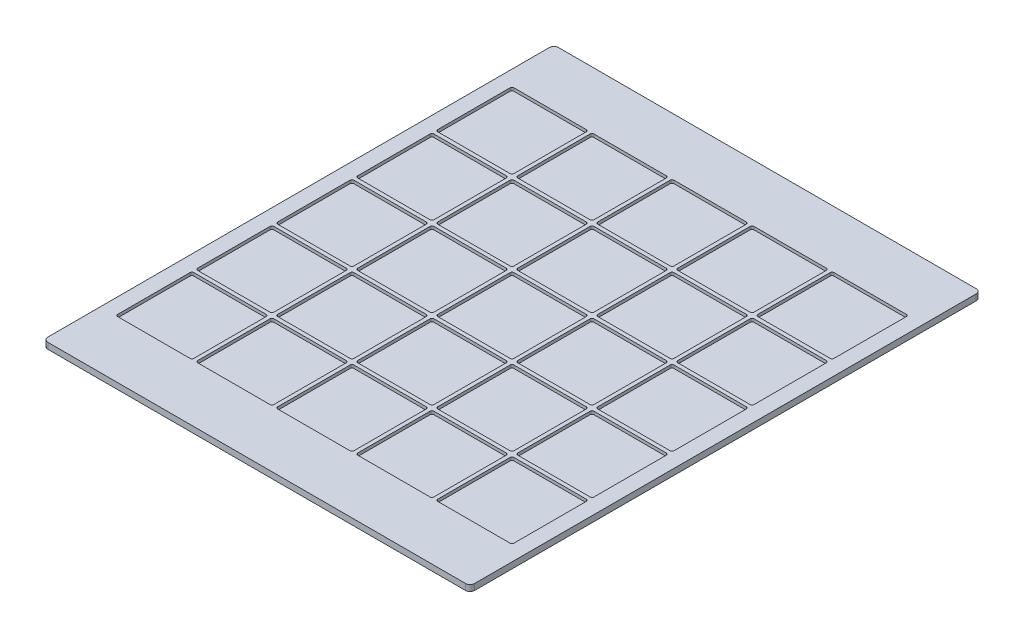
from build123d import *

# Parameters (mm, degrees)
SKETCH1_W           = 711.2
SKETCH1_H           = 850.9
BOSS_EXTRUDE1_DEPTH = 5.08
SKETCH2_W           = 711.2
SKETCH2_H           = 850.9
BOSS_EXTRUDE2_DEPTH = 5.08
FILLET1_R           = 7.62


with BuildPart() as part:
    # Sketch1 → Boss-Extrude1 (new body)
    with BuildSketch(Plane(origin=(0, 0, 0), x_dir=(1, 0, 0), z_dir=(0, 1, 0))):
        Rectangle(SKETCH1_W, SKETCH1_H)
        with BuildLine():
            Line((-193.675, 203.2), (-73.025, 203.2))
            ThreePointArc((-73.025, 203.2), (-70.77993597, 204.12993597), (-69.85, 206.375))
            Line((-69.85, 206.375), (-69.85, 327.025))
            ThreePointArc((-69.85, 327.025), (-70.77993597, 329.27006403), (-73.025, 330.2))
            Line((-73.025, 330.2), (-193.675, 330.2))
            ThreePointArc((-193.675, 330.2), (-195.92006403, 329.27006403), (-196.85, 327.025))
            Line((-196.85, 327.025), (-196.85, 206.375))
            ThreePointArc((-196.85, 206.375), (-195.92006403, 204.12993597), (-193.675, 203.2))
        make_face(mode=Mode.SUBTRACT)
        with BuildLine():
            Line((-327.025, 203.2), (-206.375, 203.2))
            ThreePointArc((-206.375, 203.2), (-204.12993597, 204.12993597), (-203.2, 206.375))
            Line((-203.2, 206.375), (-203.2, 327.025))
            ThreePointArc((-203.2, 327.025), (-204.12993597, 329.27006403), (-206.375, 330.2))
            Line((-206.375, 330.2), (-327.025, 330.2))
            ThreePointArc((-327.025, 330.2), (-329.27006403, 329.27006403), (-330.2, 327.025))
            Line((-330.2, 327.025), (-330.2, 206.375))
            ThreePointArc((-330.2, 206.375), (-329.27006403, 204.12993597), (-327.025, 203.2))
        make_face(mode=Mode.SUBTRACT)
        with BuildLine():
            Line((-60.325, 203.2), (60.325, 203.2))
            ThreePointArc((60.325, 203.2), (62.57006403, 204.12993597), (63.5, 206.375))
            Line((63.5, 206.375), (63.5, 327.025))
            ThreePointArc((63.5, 327.025), (62.57006403, 329.27006403), (60.325, 330.2))
            Line((60.325, 330.2), (-60.325, 330.2))
            ThreePointArc((-60.325, 330.2), (-62.57006403, 329.27006403), (-63.5, 327.025))
            Line((-63.5, 327.025), (-63.5, 206.375))
            ThreePointArc((-63.5, 206.375), (-62.57006403, 204.12993597), (-60.325, 203.2))
        make_face(mode=Mode.SUBTRACT)
        with BuildLine():
            Line((73.025, 203.2), (193.675, 203.2))
            ThreePointArc((193.675, 203.2), (195.92006403, 204.12993597), (196.85, 206.375))
            Line((196.85, 206.375), (196.85, 327.025))
            ThreePointArc((196.85, 327.025), (195.92006403, 329.27006403), (193.675, 330.2))
            Line((193.675, 330.2), (73.025, 330.2))
            ThreePointArc((73.025, 330.2), (70.77993597, 329.27006403), (69.85, 327.025))
            Line((69.85, 327.025), (69.85, 206.375))
            ThreePointArc((69.85, 206.375), (70.77993597, 204.12993597), (73.025, 203.2))
        make_face(mode=Mode.SUBTRACT)
        with BuildLine():
            Line((206.375, 203.2), (327.025, 203.2))
            ThreePointArc((327.025, 203.2), (329.27006403, 204.12993597), (330.2, 206.375))
            Line((330.2, 206.375), (330.2, 327.025))
            ThreePointArc((330.2, 327.025), (329.27006403, 329.27006403), (327.025, 330.2))
            Line((327.025, 330.2), (206.375, 330.2))
            ThreePointArc((206.375, 330.2), (204.12993597, 329.27006403), (203.2, 327.025))
            Line((203.2, 327.025), (203.2, 206.375))
            ThreePointArc((203.2, 206.375), (204.12993597, 204.12993597), (206.375, 203.2))
        make_face(mode=Mode.SUBTRACT)
        with BuildLine():
            Line((-193.675, 69.85), (-73.025, 69.85))
            ThreePointArc((-73.025, 69.85), (-70.77993597, 70.77993597), (-69.85, 73.025))
            Line((-69.85, 73.025), (-69.85, 193.675))
            ThreePointArc((-69.85, 193.675), (-70.77993597, 195.92006403), (-73.025, 196.85))
            Line((-73.025, 196.85), (-193.675, 196.85))
            ThreePointArc((-193.675, 196.85), (-195.92006403, 195.92006403), (-196.85, 193.675))
            Line((-196.85, 193.675), (-196.85, 73.025))
            ThreePointArc((-196.85, 73.025), (-195.92006403, 70.77993597), (-193.675, 69.85))
        make_face(mode=Mode.SUBTRACT)
        with BuildLine():
            Line((-60.325, 69.85), (60.325, 69.85))
            ThreePointArc((60.325, 69.85), (62.57006403, 70.77993597), (63.5, 73.025))
            Line((63.5, 73.025), (63.5, 193.675))
            ThreePointArc((63.5, 193.675), (62.57006403, 195.92006403), (60.325, 196.85))
            Line((60.325, 196.85), (-60.325, 196.85))
            ThreePointArc((-60.325, 196.85), (-62.57006403, 195.92006403), (-63.5, 193.675))
            Line((-63.5, 193.675), (-63.5, 73.025))
            ThreePointArc((-63.5, 73.025), (-62.57006403, 70.77993597), (-60.325, 69.85))
        make_face(mode=Mode.SUBTRACT)
        with BuildLine():
            Line((73.025, 69.85), (193.675, 69.85))
            ThreePointArc((193.675, 69.85), (195.92006403, 70.77993597), (196.85, 73.025))
            Line((196.85, 73.025), (196.85, 193.675))
            ThreePointArc((196.85, 193.675), (195.92006403, 195.92006403), (193.675, 196.85))
            Line((193.675, 196.85), (73.025, 196.85))
            ThreePointArc((73.025, 196.85), (70.77993597, 195.92006403), (69.85, 193.675))
            Line((69.85, 193.675), (69.85, 73.025))
            ThreePointArc((69.85, 73.025), (70.77993597, 70.77993597), (73.025, 69.85))
        make_face(mode=Mode.SUBTRACT)
        with BuildLine():
            Line((206.375, 69.85), (327.025, 69.85))
            ThreePointArc((327.025, 69.85), (329.27006403, 70.77993597), (330.2, 73.025))
            Line((330.2, 73.025), (330.2, 193.675))
            ThreePointArc((330.2, 193.675), (329.27006403, 195.92006403), (327.025, 196.85))
            Line((327.025, 196.85), (206.375, 196.85))
            ThreePointArc((206.375, 196.85), (204.12993597, 195.92006403), (203.2, 193.675))
            Line((203.2, 193.675), (203.2, 73.025))
            ThreePointArc((203.2, 73.025), (204.12993597, 70.77993597), (206.375, 69.85))
        make_face(mode=Mode.SUBTRACT)
        with BuildLine():
            Line((-193.675, -63.5), (-73.025, -63.5))
            ThreePointArc((-73.025, -63.5), (-70.77993597, -62.57006403), (-69.85, -60.325))
            Line((-69.85, -60.325), (-69.85, 60.325))
            ThreePointArc((-69.85, 60.325), (-70.77993597, 62.57006403), (-73.025, 63.5))
            Line((-73.025, 63.5), (-193.675, 63.5))
            ThreePointArc((-193.675, 63.5), (-195.92006403, 62.57006403), (-196.85, 60.325))
            Line((-196.85, 60.325), (-196.85, -60.325))
            ThreePointArc((-196.85, -60.325), (-195.92006403, -62.57006403), (-193.675, -63.5))
        make_face(mode=Mode.SUBTRACT)
        with BuildLine():
            Line((-60.325, -63.5), (60.325, -63.5))
            ThreePointArc((60.325, -63.5), (62.57006403, -62.57006403), (63.5, -60.325))
            Line((63.5, -60.325), (63.5, 60.325))
            ThreePointArc((63.5, 60.325), (62.57006403, 62.57006403), (60.325, 63.5))
            Line((60.325, 63.5), (-60.325, 63.5))
            ThreePointArc((-60.325, 63.5), (-62.57006403, 62.57006403), (-63.5, 60.325))
            Line((-63.5, 60.325), (-63.5, -60.325))
            ThreePointArc((-63.5, -60.325), (-62.57006403, -62.57006403), (-60.325, -63.5))
        make_face(mode=Mode.SUBTRACT)
        with BuildLine():
            Line((73.025, -63.5), (193.675, -63.5))
            ThreePointArc((193.675, -63.5), (195.92006403, -62.57006403), (196.85, -60.325))
            Line((196.85, -60.325), (196.85, 60.325))
            ThreePointArc((196.85, 60.325), (195.92006403, 62.57006403), (193.675, 63.5))
            Line((193.675, 63.5), (73.025, 63.5))
            ThreePointArc((73.025, 63.5), (70.77993597, 62.57006403), (69.85, 60.325))
            Line((69.85, 60.325), (69.85, -60.325))
            ThreePointArc((69.85, -60.325), (70.77993597, -62.57006403), (73.025, -63.5))
        make_face(mode=Mode.SUBTRACT)
        with BuildLine():
            Line((206.375, -63.5), (327.025, -63.5))
            ThreePointArc((327.025, -63.5), (329.27006403, -62.57006403), (330.2, -60.325))
            Line((330.2, -60.325), (330.2, 60.325))
            ThreePointArc((330.2, 60.325), (329.27006403, 62.57006403), (327.025, 63.5))
            Line((327.025, 63.5), (206.375, 63.5))
            ThreePointArc((206.375, 63.5), (204.12993597, 62.57006403), (203.2, 60.325))
            Line((203.2, 60.325), (203.2, -60.325))
            ThreePointArc((203.2, -60.325), (204.12993597, -62.57006403), (206.375, -63.5))
        make_face(mode=Mode.SUBTRACT)
        with BuildLine():
            Line((-193.675, -196.85), (-73.025, -196.85))
            ThreePointArc((-73.025, -196.85), (-70.77993597, -195.92006403), (-69.85, -193.675))
            Line((-69.85, -193.675), (-69.85, -73.025))
            ThreePointArc((-69.85, -73.025), (-70.77993597, -70.77993597), (-73.025, -69.85))
            Line((-73.025, -69.85), (-193.675, -69.85))
            ThreePointArc((-193.675, -69.85), (-195.92006403, -70.77993597), (-196.85, -73.025))
            Line((-196.85, -73.025), (-196.85, -193.675))
            ThreePointArc((-196.85, -193.675), (-195.92006403, -195.92006403), (-193.675, -196.85))
        make_face(mode=Mode.SUBTRACT)
        with BuildLine():
            Line((-60.325, -196.85), (60.325, -196.85))
            ThreePointArc((60.325, -196.85), (62.57006403, -195.92006403), (63.5, -193.675))
            Line((63.5, -193.675), (63.5, -73.025))
            ThreePointArc((63.5, -73.025), (62.57006403, -70.77993597), (60.325, -69.85))
            Line((60.325, -69.85), (-60.325, -69.85))
            ThreePointArc((-60.325, -69.85), (-62.57006403, -70.77993597), (-63.5, -73.025))
            Line((-63.5, -73.025), (-63.5, -193.675))
            ThreePointArc((-63.5, -193.675), (-62.57006403, -195.92006403), (-60.325, -196.85))
        make_face(mode=Mode.SUBTRACT)
        with BuildLine():
            Line((73.025, -196.85), (193.675, -196.85))
            ThreePointArc((193.675, -196.85), (195.92006403, -195.92006403), (196.85, -193.675))
            Line((196.85, -193.675), (196.85, -73.025))
            ThreePointArc((196.85, -73.025), (195.92006403, -70.77993597), (193.675, -69.85))
            Line((193.675, -69.85), (73.025, -69.85))
            ThreePointArc((73.025, -69.85), (70.77993597, -70.77993597), (69.85, -73.025))
            Line((69.85, -73.025), (69.85, -193.675))
            ThreePointArc((69.85, -193.675), (70.77993597, -195.92006403), (73.025, -196.85))
        make_face(mode=Mode.SUBTRACT)
        with BuildLine():
            Line((206.375, -196.85), (327.025, -196.85))
            ThreePointArc((327.025, -196.85), (329.27006403, -195.92006403), (330.2, -193.675))
            Line((330.2, -193.675), (330.2, -73.025))
            ThreePointArc((330.2, -73.025), (329.27006403, -70.77993597), (327.025, -69.85))
            Line((327.025, -69.85), (206.375, -69.85))
            ThreePointArc((206.375, -69.85), (204.12993597, -70.77993597), (203.2, -73.025))
            Line((203.2, -73.025), (203.2, -193.675))
            ThreePointArc((203.2, -193.675), (204.12993597, -195.92006403), (206.375, -196.85))
        make_face(mode=Mode.SUBTRACT)
        with BuildLine():
            Line((-193.675, -330.2), (-73.025, -330.2))
            ThreePointArc((-73.025, -330.2), (-70.77993597, -329.27006403), (-69.85, -327.025))
            Line((-69.85, -327.025), (-69.85, -206.375))
            ThreePointArc((-69.85, -206.375), (-70.77993597, -204.12993597), (-73.025, -203.2))
            Line((-73.025, -203.2), (-193.675, -203.2))
            ThreePointArc((-193.675, -203.2), (-195.92006403, -204.12993597), (-196.85, -206.375))
            Line((-196.85, -206.375), (-196.85, -327.025))
            ThreePointArc((-196.85, -327.025), (-195.92006403, -329.27006403), (-193.675, -330.2))
        make_face(mode=Mode.SUBTRACT)
        with BuildLine():
            Line((-60.325, -330.2), (60.325, -330.2))
            ThreePointArc((60.325, -330.2), (62.57006403, -329.27006403), (63.5, -327.025))
            Line((63.5, -327.025), (63.5, -206.375))
            ThreePointArc((63.5, -206.375), (62.57006403, -204.12993597), (60.325, -203.2))
            Line((60.325, -203.2), (-60.325, -203.2))
            ThreePointArc((-60.325, -203.2), (-62.57006403, -204.12993597), (-63.5, -206.375))
            Line((-63.5, -206.375), (-63.5, -327.025))
            ThreePointArc((-63.5, -327.025), (-62.57006403, -329.27006403), (-60.325, -330.2))
        make_face(mode=Mode.SUBTRACT)
        with BuildLine():
            Line((73.025, -330.2), (193.675, -330.2))
            ThreePointArc((193.675, -330.2), (195.92006403, -329.27006403), (196.85, -327.025))
            Line((196.85, -327.025), (196.85, -206.375))
            ThreePointArc((196.85, -206.375), (195.92006403, -204.12993597), (193.675, -203.2))
            Line((193.675, -203.2), (73.025, -203.2))
            ThreePointArc((73.025, -203.2), (70.77993597, -204.12993597), (69.85, -206.375))
            Line((69.85, -206.375), (69.85, -327.025))
            ThreePointArc((69.85, -327.025), (70.77993597, -329.27006403), (73.025, -330.2))
        make_face(mode=Mode.SUBTRACT)
        with BuildLine():
            Line((206.375, -330.2), (327.025, -330.2))
            ThreePointArc((327.025, -330.2), (329.27006403, -329.27006403), (330.2, -327.025))
            Line((330.2, -327.025), (330.2, -206.375))
            ThreePointArc((330.2, -206.375), (329.27006403, -204.12993597), (327.025, -203.2))
            Line((327.025, -203.2), (206.375, -203.2))
            ThreePointArc((206.375, -203.2), (204.12993597, -204.12993597), (203.2, -206.375))
            Line((203.2, -206.375), (203.2, -327.025))
            ThreePointArc((203.2, -327.025), (204.12993597, -329.27006403), (206.375, -330.2))
        make_face(mode=Mode.SUBTRACT)
        with BuildLine():
            Line((-327.025, 69.85), (-206.375, 69.85))
            ThreePointArc((-206.375, 69.85), (-204.12993597, 70.77993597), (-203.2, 73.025))
            Line((-203.2, 73.025), (-203.2, 193.675))
            ThreePointArc((-203.2, 193.675), (-204.12993597, 195.92006403), (-206.375, 196.85))
            Line((-206.375, 196.85), (-327.025, 196.85))
            ThreePointArc((-327.025, 196.85), (-329.27006403, 195.92006403), (-330.2, 193.675))
            Line((-330.2, 193.675), (-330.2, 73.025))
            ThreePointArc((-330.2, 73.025), (-329.27006403, 70.77993597), (-327.025, 69.85))
        make_face(mode=Mode.SUBTRACT)
        with BuildLine():
            Line((-327.025, -63.5), (-206.375, -63.5))
            ThreePointArc((-206.375, -63.5), (-204.12993597, -62.57006403), (-203.2, -60.325))
            Line((-203.2, -60.325), (-203.2, 60.325))
            ThreePointArc((-203.2, 60.325), (-204.12993597, 62.57006403), (-206.375, 63.5))
            Line((-206.375, 63.5), (-327.025, 63.5))
            ThreePointArc((-327.025, 63.5), (-329.27006403, 62.57006403), (-330.2, 60.325))
            Line((-330.2, 60.325), (-330.2, -60.325))
            ThreePointArc((-330.2, -60.325), (-329.27006403, -62.57006403), (-327.025, -63.5))
        make_face(mode=Mode.SUBTRACT)
        with BuildLine():
            Line((-327.025, -196.85), (-206.375, -196.85))
            ThreePointArc((-206.375, -196.85), (-204.12993597, -195.92006403), (-203.2, -193.675))
            Line((-203.2, -193.675), (-203.2, -73.025))
            ThreePointArc((-203.2, -73.025), (-204.12993597, -70.77993597), (-206.375, -69.85))
            Line((-206.375, -69.85), (-327.025, -69.85))
            ThreePointArc((-327.025, -69.85), (-329.27006403, -70.77993597), (-330.2, -73.025))
            Line((-330.2, -73.025), (-330.2, -193.675))
            ThreePointArc((-330.2, -193.675), (-329.27006403, -195.92006403), (-327.025, -196.85))
        make_face(mode=Mode.SUBTRACT)
        with BuildLine():
            Line((-327.025, -330.2), (-206.375, -330.2))
            ThreePointArc((-206.375, -330.2), (-204.12993597, -329.27006403), (-203.2, -327.025))
            Line((-203.2, -327.025), (-203.2, -206.375))
            ThreePointArc((-203.2, -206.375), (-204.12993597, -204.12993597), (-206.375, -203.2))
            Line((-206.375, -203.2), (-327.025, -203.2))
            ThreePointArc((-327.025, -203.2), (-329.27006403, -204.12993597), (-330.2, -206.375))
            Line((-330.2, -206.375), (-330.2, -327.025))
            ThreePointArc((-330.2, -327.025), (-329.27006403, -329.27006403), (-327.025, -330.2))
        make_face(mode=Mode.SUBTRACT)
    extrude(amount=BOSS_EXTRUDE1_DEPTH)

    # Sketch2 → Boss-Extrude2 (add)
    with BuildSketch(Plane.XZ):
        Rectangle(SKETCH2_W, SKETCH2_H)
    extrude(amount=BOSS_EXTRUDE2_DEPTH)

    # Fillet1
    fillet1_edges = [part.edges().sort_by_distance(p)[0] for p in [
        (355.6, 0, 425.45),
        (-355.6, 0, 425.45),
        (-355.6, 0, -425.45),
        (355.6, 0, -425.45),
    ]]
    fillet(fillet1_edges, radius=FILLET1_R)


solid = part.part
